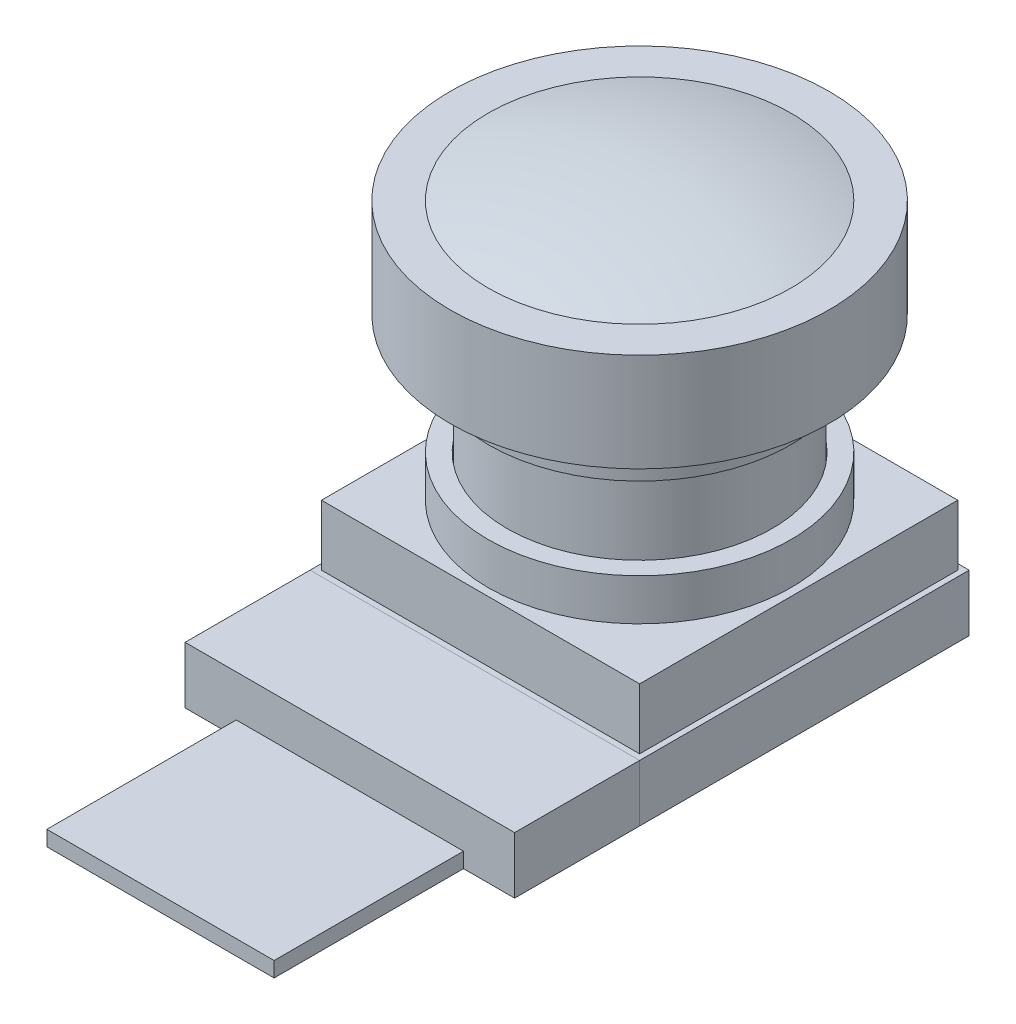
from build123d import *

# Parameters (mm, degrees)
SKETCH_1_W          = 8.7
SKETCH_1_H          = 8.7
EXTRUDE_1_DEPTH     = 3.1
SKETCH_2_R          = 4
SKETCH_2_R_2        = 3.5
EXTRUDE_2_DEPTH     = 1.1
SKETCH_3_R          = 3.48
EXTRUDE_3_DEPTH     = 6.85
SKETCH_4_R          = 5
EXTRUDE_4_DEPTH     = 2.6
SKETCH_5_W          = 8.7
SKETCH_5_H          = 1.5
EXTRUDE_5_DEPTH     = 3.3
SKETCH_10_W         = 6
SKETCH_10_H         = 5
EXTRUDE_6_DEPTH     = 0.4
SKETCH_13_W         = 8.7
SKETCH_13_H         = 8.7
SKETCH_13_W_2       = 8.4
SKETCH_13_H_2       = 8.4
CUT_EXTRUDE_1_DEPTH = 1.6
SKETCH_14_R         = 3.98
SKETCH_14_R_2       = 3.48
EXTRUDE_7_DEPTH     = 1


with BuildPart() as part:
    # 草图1 → 凸台-拉伸1 (new body)
    with BuildSketch(Plane(origin=(0, 0, 0), x_dir=(1, 0, 0), z_dir=(0, 1, 0))):
        Rectangle(SKETCH_1_W, SKETCH_1_H)
    extrude(amount=EXTRUDE_1_DEPTH)

    # 草图2 → 凸台-拉伸2 (add)
    with BuildSketch(Plane(origin=(0, 3.1, 0), x_dir=(1, 0, 0), z_dir=(0, 1, 0))):
        Circle(SKETCH_2_R)
        Circle(SKETCH_2_R_2, mode=Mode.SUBTRACT)
    extrude(amount=EXTRUDE_2_DEPTH)

    # 草图3 → 凸台-拉伸3 (add)
    with BuildSketch(Plane(origin=(0, 3.1, 0), x_dir=(1, 0, 0), z_dir=(0, 1, 0))):
        Circle(SKETCH_3_R)
    extrude(amount=EXTRUDE_3_DEPTH)

    # 草图4 → 凸台-拉伸4 (add)
    with BuildSketch(Plane(origin=(0, 9.95, 0), x_dir=(1, 0, 0), z_dir=(0, 1, 0))):
        Circle(SKETCH_4_R)
    extrude(amount=-EXTRUDE_4_DEPTH)

    # 草图13 → 切除-拉伸1 (cut)
    with BuildSketch(Plane(origin=(0, 3.1, 0), x_dir=(1, 0, 0), z_dir=(0, 1, 0))):
        Rectangle(SKETCH_13_W, SKETCH_13_H)
        Rectangle(SKETCH_13_W_2, SKETCH_13_H_2, mode=Mode.SUBTRACT)
    extrude(amount=-CUT_EXTRUDE_1_DEPTH, mode=Mode.SUBTRACT)

    # 草图14 → 凸台-拉伸7 (add)
    with BuildSketch(Plane.XZ.offset(-7.35)):
        Circle(SKETCH_14_R)
        Circle(SKETCH_14_R_2, mode=Mode.SUBTRACT)
    extrude(amount=EXTRUDE_7_DEPTH)

    # 草图11 → 旋转3 (revolve)
    with BuildSketch(Plane.XY):
        with BuildLine():
            Line((0, 9.95), (-4, 9.95))
            ThreePointArc((-4, 9.95), (-2.022374842, 10.399165611), (0, 10.55))
            Line((0, 10.55), (0, 9.95))
        make_face()
    revolve(axis=Axis((0, 9.95, 0), (0, -1, 0)))


with BuildPart() as body_2:
    # 草图5 → 凸台-拉伸5 (new body)
    with BuildSketch(Plane.XY.offset(4.35)):
        with Locations((0, 0.75)):
            Rectangle(SKETCH_5_W, SKETCH_5_H)
    extrude(amount=EXTRUDE_5_DEPTH)


with BuildPart() as body_3:
    # 草图10 → 凸台-拉伸6 (new body)
    with BuildSketch(Plane(origin=(0, 0, 0), x_dir=(1, 0, 0), z_dir=(0, 1, 0))):
        with Locations((0, -10.15)):
            Rectangle(SKETCH_10_W, SKETCH_10_H)
    extrude(amount=EXTRUDE_6_DEPTH)


solid = Compound([part.part, body_2.part, body_3.part])
